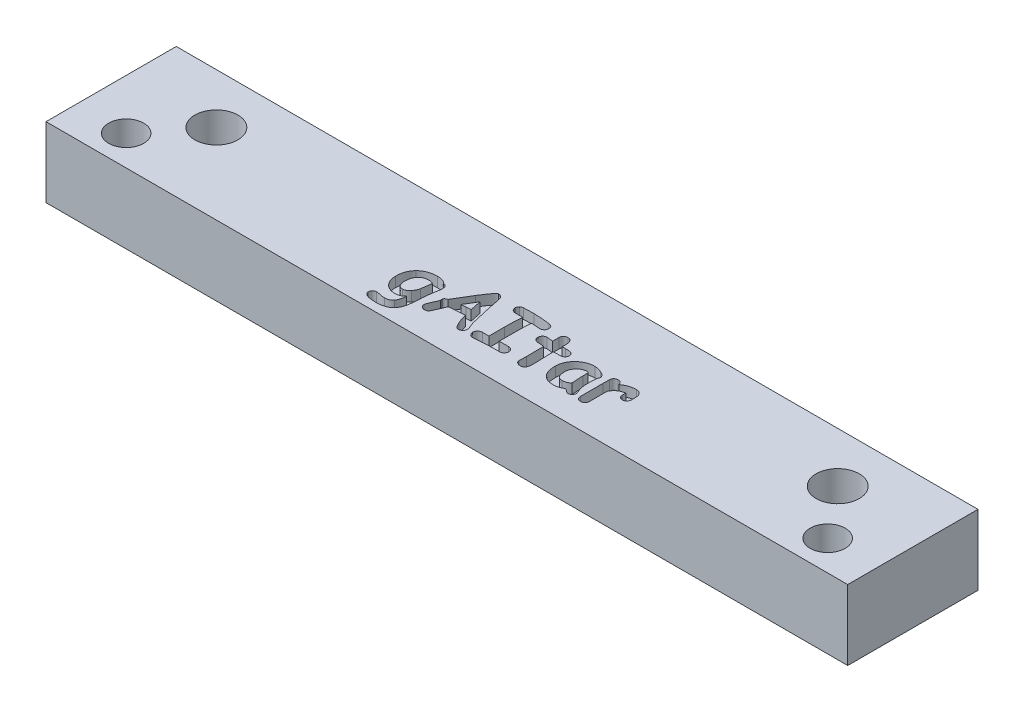
from build123d import *

# Parameters (mm, degrees)
SKETCH1_R           = 1.75
SKETCH1_R_2         = 2.15
BOSS_EXTRUDE1_DEPTH = 7
CUT_EXTRUDE1_DEPTH  = 1


with BuildPart() as part:
    # Sketch1 → Boss-Extrude1 (new body)
    with BuildSketch(Plane(origin=(0, 0, 0), x_dir=(1, 0, 0), z_dir=(0, 1, 0))):
        Polygon((-5.262861358, -24.280752379), (74.737138642, -24.280752379), (74.737138642, -37.280752379), (-5.262861358, -37.280752379), (-5.262861358, -36.780752379), align=None)
        with Locations((-0.262861358, -34.280752379)):
            Circle(SKETCH1_R, mode=Mode.SUBTRACT)
        with Locations((69.737138642, -34.280752379)):
            Circle(SKETCH1_R, mode=Mode.SUBTRACT)
        with Locations((3.737138642, -29.280752379)):
            Circle(SKETCH1_R_2, mode=Mode.SUBTRACT)
        with Locations((65.737138642, -29.280752379)):
            Circle(SKETCH1_R_2, mode=Mode.SUBTRACT)
    extrude(amount=-BOSS_EXTRUDE1_DEPTH)

    # Sketch2 → Cut-Extrude1 (cut)
    with BuildSketch(Plane(origin=(0, 0, 0), x_dir=(1, 0, 0), z_dir=(0, 1, 0))):
        with BuildLine():
            add(Edge.make_bspline(
                [(28.877942793, -32.540894307), (28.854196843, -32.673953942), (28.806150163, -32.943181901), (28.756806812, -33.35489831), (28.717322684, -33.776893115), (28.705414659, -34.062125424), (28.699392645, -34.20637041)],
                knots=[0, 0, 0, 0, 0.000405405, 0.000820281, 0.00124354, 0.001676578, 0.001676578, 0.001676578, 0.001676578], degree=3))
            add(Edge.make_bspline(
                [(28.699392645, -34.20637041), (28.695835472, -34.293705449), (28.688967863, -34.462317677), (28.66700685, -34.705919532), (28.636730362, -34.931090951), (28.597753156, -35.138010913), (28.548415725, -35.32603197), (28.489788382, -35.495464519), (28.423852115, -35.647606206), (28.368742547, -35.738131355), (28.342292349, -35.781579494)],
                knots=[0, 0, 0, 0, 0.000262191, 0.000506195, 0.000733457, 0.000943562, 0.001137489, 0.001315987, 0.001481163, 0.001633607, 0.001633607, 0.001633607, 0.001633607], degree=3))
            add(Edge.make_bspline(
                [(28.342292349, -35.781579494), (28.304156717, -35.834120572), (28.228319149, -35.93860521), (28.08648839, -36.07296206), (27.924012281, -36.185281957), (27.741415791, -36.278633239), (27.537219472, -36.349224454), (27.31309504, -36.400339071), (27.06817942, -36.431391059), (26.898115345, -36.434597207), (26.809736912, -36.43626337)],
                knots=[0, 0, 0, 0, 0.000194444, 0.000386677, 0.000582603, 0.000785341, 0.000999932, 0.001229002, 0.001473967, 0.001739002, 0.001739002, 0.001739002, 0.001739002], degree=3))
            add(Edge.make_bspline(
                [(26.809736912, -36.43626337), (26.757822527, -36.435865226), (26.65726388, -36.435094018), (26.511633725, -36.429685898), (26.376108667, -36.418024576), (26.250493435, -36.40523917), (26.135011767, -36.386120244), (26.029697641, -36.363469033), (25.93389223, -36.337336662), (25.848744625, -36.305110889), (25.7722405, -36.271205713), (25.706915296, -36.231051948), (25.650032596, -36.188884639), (25.604453101, -36.140433156), (25.569924709, -36.087279093), (25.543039988, -36.031277274), (25.527858641, -35.970176707), (25.526080351, -35.928137653), (25.525167791, -35.906564597)],
                knots=[0, 0, 0, 0, 0.000155748, 0.000301685, 0.000437031, 0.000563771, 0.00068037, 0.000787963, 0.000886884, 0.000977905, 0.001060903, 0.001137457, 0.001207493, 0.001272758, 0.00133576, 0.001397004, 0.001458353, 0.00152302, 0.00152302, 0.00152302, 0.00152302], degree=3))
            add(Edge.make_bspline(
                [(25.525167791, -35.906564597), (25.526215877, -35.87629543), (25.528227825, -35.818189517), (25.551639504, -35.736146405), (25.585673774, -35.661923106), (25.636625425, -35.599198201), (25.697788314, -35.547064507), (25.769772825, -35.510032387), (25.85046819, -35.487192991), (25.907236411, -35.485091336), (25.936825077, -35.483995914)],
                knots=[0, 0, 0, 0, 9.0534e-05, 0.000173792, 0.000254097, 0.000333879, 0.000414147, 0.000493565, 0.00057491, 0.000663466, 0.000663466, 0.000663466, 0.000663466], degree=3))
            add(Edge.make_bspline(
                [(25.936825077, -35.483995914), (25.963638071, -35.484919846), (26.023093997, -35.4869686), (26.119754504, -35.499958035), (26.232260846, -35.519849823), (26.355963241, -35.548043262), (26.484090778, -35.575933949), (26.609257658, -35.595667814), (26.726478353, -35.608437094), (26.802102599, -35.610143535), (26.838503324, -35.610964908)],
                knots=[0, 0, 0, 0, 8.0445e-05, 0.000178382, 0.000292214, 0.000423155, 0.000558946, 0.000685496, 0.000803149, 0.000912335, 0.000912335, 0.000912335, 0.000912335], degree=3))
            add(Edge.make_bspline(
                [(26.838503324, -35.610964908), (26.877567932, -35.610011313), (26.953309544, -35.608162407), (27.062525339, -35.594017403), (27.164376647, -35.571929801), (27.25734991, -35.537443735), (27.344008004, -35.49628974), (27.421574401, -35.443913826), (27.492510687, -35.383376968), (27.531879254, -35.335510928), (27.551711971, -35.311397437)],
                knots=[0, 0, 0, 0, 0.000117155, 0.000227149, 0.0003299, 0.000429055, 0.000523992, 0.000616981, 0.000709083, 0.000802584, 0.000802584, 0.000802584, 0.000802584], degree=3))
            add(Edge.make_bspline(
                [(27.551711971, -35.311397437), (27.569896668, -35.285681108), (27.60765942, -35.232277999), (27.653002314, -35.141279861), (27.694315296, -35.040298892), (27.727996695, -34.928090612), (27.758259393, -34.805399974), (27.781516807, -34.671465868), (27.799232941, -34.52642129), (27.806731843, -34.425959905), (27.810609686, -34.37400916)],
                knots=[0, 0, 0, 0, 9.4365e-05, 0.000195961, 0.000304088, 0.000421431, 0.000547017, 0.000683029, 0.00082895, 0.000985218, 0.000985218, 0.000985218, 0.000985218], degree=3))
            add(Edge.make_bspline(
                [(27.810609686, -34.37400916), (27.782698885, -34.401695192), (27.727347747, -34.456600581), (27.636014673, -34.528050168), (27.538772831, -34.587668052), (27.437572584, -34.637986756), (27.330231435, -34.675859988), (27.218052679, -34.701888829), (27.10129262, -34.720035356), (27.021753856, -34.72145877), (26.981343443, -34.722181949)],
                knots=[0, 0, 0, 0, 0.00011787, 0.000233754, 0.000346892, 0.000459573, 0.000572206, 0.000687451, 0.000804727, 0.000925846, 0.000925846, 0.000925846, 0.000925846], degree=3))
            add(Edge.make_bspline(
                [(26.981343443, -34.722181949), (26.928715985, -34.720777789), (26.825393462, -34.718021028), (26.67399483, -34.698437024), (26.530566129, -34.66336396), (26.394723539, -34.615394255), (26.265617077, -34.555215108), (26.145466336, -34.478931655), (26.032337381, -34.389967924), (25.927914025, -34.28800268), (25.833018923, -34.176043267), (25.751475247, -34.054333172), (25.680007527, -33.926616585), (25.624071676, -33.789363081), (25.578603755, -33.64556891), (25.549151631, -33.493399956), (25.527776408, -33.334724057), (25.526047619, -33.226074351), (25.525167791, -33.170779552)],
                knots=[0, 0, 0, 0, 0.000157872, 0.000309947, 0.000456946, 0.000600007, 0.000741553, 0.00088329, 0.001025971, 0.001172581, 0.001320418, 0.001465408, 0.00161147, 0.00175866, 0.001909259, 0.002063139, 0.002223085, 0.002388847, 0.002388847, 0.002388847, 0.002388847], degree=3))
            add(Edge.make_bspline(
                [(25.525167791, -33.170779552), (25.526887554, -33.096306694), (25.530261295, -32.950209702), (25.556533664, -32.736791613), (25.59873183, -32.534061071), (25.659225728, -32.342452474), (25.738560907, -32.162235251), (25.832463145, -31.991635336), (25.944982803, -31.832194811), (26.033254821, -31.736816392), (26.077681305, -31.688813323)],
                knots=[0, 0, 0, 0, 0.000223366, 0.000438188, 0.000644021, 0.000843855, 0.001039754, 0.001233795, 0.001427288, 0.001623345, 0.001623345, 0.001623345, 0.001623345], degree=3))
            add(Edge.make_bspline(
                [(26.077681305, -31.688813323), (26.126623805, -31.642038529), (26.223993806, -31.54898113), (26.387583037, -31.429806694), (26.562833435, -31.327778035), (26.751348872, -31.245446265), (26.952265678, -31.18185141), (27.165544243, -31.136712361), (27.391232899, -31.108125262), (27.546002792, -31.105107959), (27.625115921, -31.103565616)],
                knots=[0, 0, 0, 0, 0.000202913, 0.00040369, 0.000605473, 0.000810232, 0.001019476, 0.001236601, 0.001463479, 0.001700722, 0.001700722, 0.001700722, 0.001700722], degree=3))
            add(Edge.make_bspline(
                [(27.625115921, -31.103565616), (27.675732098, -31.104560502), (27.773198918, -31.106476261), (27.914326626, -31.119895566), (28.044017457, -31.144722103), (28.1634328, -31.178290006), (28.271952343, -31.221458981), (28.369629058, -31.275733024), (28.45670153, -31.339917156), (28.506269461, -31.390857667), (28.530761949, -31.416028375)],
                knots=[0, 0, 0, 0, 0.000151849, 0.000292401, 0.000424691, 0.000547456, 0.000664055, 0.000774178, 0.000881904, 0.000987125, 0.000987125, 0.000987125, 0.000987125], degree=3))
            add(Edge.make_bspline(
                [(28.530761949, -31.416028375), (28.56412149, -31.42109757), (28.627553929, -31.430736535), (28.714583395, -31.46367469), (28.78972595, -31.506896655), (28.850939812, -31.564983183), (28.897308072, -31.636572375), (28.929698255, -31.720321457), (28.949743161, -31.81617478), (28.952092305, -31.884119952), (28.953330633, -31.91993657)],
                knots=[0, 0, 0, 0, 0.000100969, 0.000191991, 0.00027739, 0.000359482, 0.000442569, 0.000531169, 0.00062747, 0.000734825, 0.000734825, 0.000734825, 0.000734825], degree=3))
            add(Edge.make_bspline(
                [(28.953330633, -31.91993657), (28.952146673, -31.960964891), (28.949572935, -32.050153848), (28.93454218, -32.194803585), (28.910557112, -32.360819589), (28.889249419, -32.478466591), (28.877942793, -32.540894307)],
                knots=[0, 0, 0, 0, 0.000123101, 0.000267602, 0.000435941, 0.000626255, 0.000626255, 0.000626255, 0.000626255], degree=3))
        make_face()
        with BuildLine():
            add(Edge.make_bspline(
                [(27.56659115, -31.865379581), (27.520897879, -31.866438657), (27.432118229, -31.868496386), (27.302839553, -31.886893976), (27.181391398, -31.916335625), (27.06739643, -31.957997772), (26.961687428, -32.012408784), (26.862456622, -32.076515818), (26.772331692, -32.154971826), (26.719478595, -32.214911306), (26.69268737, -32.245294618)],
                knots=[0, 0, 0, 0, 0.000137018, 0.000266218, 0.000390841, 0.000511353, 0.000629357, 0.000746834, 0.000864972, 0.000986415, 0.000986415, 0.000986415, 0.000986415], degree=3))
            add(Edge.make_bspline(
                [(26.69268737, -32.245294618), (26.670222313, -32.274607183), (26.625110774, -32.333469041), (26.568683583, -32.430563617), (26.521696421, -32.533923157), (26.480705607, -32.642858454), (26.452158703, -32.758926344), (26.430185117, -32.880815208), (26.41555868, -33.00907014), (26.414495131, -33.097003963), (26.41395075, -33.142013139)],
                knots=[0, 0, 0, 0, 0.000110707, 0.000222309, 0.000335929, 0.000451101, 0.000570914, 0.000693883, 0.000822595, 0.000957558, 0.000957558, 0.000957558, 0.000957558], degree=3))
            add(Edge.make_bspline(
                [(26.41395075, -33.142013139), (26.414223247, -33.175091726), (26.414749831, -33.23901425), (26.421850576, -33.331757851), (26.433363121, -33.417972092), (26.450416552, -33.497773343), (26.471296862, -33.571312332), (26.495229735, -33.639403995), (26.526734343, -33.699997687), (26.561304149, -33.755246201), (26.600972494, -33.804231754), (26.645911755, -33.845995073), (26.695443236, -33.881633978), (26.750140152, -33.909882252), (26.808830778, -33.933163075), (26.87257302, -33.948767141), (26.940667904, -33.959026479), (26.987916632, -33.959913895), (27.012093746, -33.960367984)],
                knots=[0, 0, 0, 0, 9.9214e-05, 0.000191726, 0.000278843, 0.00035997, 0.000436273, 0.000508139, 0.000576013, 0.00064068, 0.000703424, 0.000764483, 0.000824214, 0.00088589, 0.000948705, 0.001013181, 0.001082341, 0.001154814, 0.001154814, 0.001154814, 0.001154814], degree=3))
            add(Edge.make_bspline(
                [(27.012093746, -33.960367984), (27.035019407, -33.959534524), (27.081094772, -33.957859458), (27.149436886, -33.940123073), (27.218547523, -33.915948552), (27.286972543, -33.879200372), (27.356099105, -33.833464902), (27.42382951, -33.775837691), (27.494234949, -33.711012696), (27.537326333, -33.660944897), (27.559647533, -33.635009936)],
                knots=[0, 0, 0, 0, 6.8624e-05, 0.000137918, 0.000210716, 0.000287916, 0.000370176, 0.000458954, 0.000554387, 0.000656946, 0.000656946, 0.000656946, 0.000656946], degree=3))
            add(Edge.make_bspline(
                [(27.559647533, -33.635009936), (27.599829018, -33.58478111), (27.676709488, -33.488676753), (27.763963056, -33.333776212), (27.828525089, -33.181333794), (27.846515602, -33.076726335), (27.855247223, -33.025955543)],
                knots=[0, 0, 0, 0, 0.000192637, 0.000368578, 0.000531963, 0.000686044, 0.000686044, 0.000686044, 0.000686044], degree=3))
            add(Edge.make_bspline(
                [(27.855247223, -33.025955543), (27.860580778, -32.996535701), (27.871897159, -32.934114644), (27.888912402, -32.834990839), (27.905600452, -32.724135401), (27.923143748, -32.602081561), (27.942567757, -32.468289936), (27.960799418, -32.323005644), (27.980794396, -32.166298982), (27.994157711, -32.058152502), (28.001063177, -32.002268027)],
                knots=[0, 0, 0, 0, 8.9698e-05, 0.000190316, 0.000301706, 0.000425996, 0.000560246, 0.000707275, 0.000865253, 0.001034181, 0.001034181, 0.001034181, 0.001034181], degree=3))
            add(Edge.make_bspline(
                [(28.001063177, -32.002268027), (27.964183764, -31.981414951), (27.892722474, -31.941007915), (27.781348127, -31.899037579), (27.673103957, -31.871040303), (27.601466585, -31.867233068), (27.56659115, -31.865379581)],
                knots=[0, 0, 0, 0, 0.000126911, 0.000245915, 0.000356106, 0.000460642, 0.000460642, 0.000460642, 0.000460642], degree=3))
        make_face(mode=Mode.SUBTRACT)
        with BuildLine():
            add(Edge.make_bspline(
                [(33.235558349, -34.658697452), (33.213085251, -34.655922999), (33.16579916, -34.650085219), (33.097271021, -34.615554786), (33.030235064, -34.561916936), (32.963029355, -34.489879395), (32.897121064, -34.398047027), (32.829245877, -34.288319318), (32.762560867, -34.158249172), (32.720891322, -34.063762617), (32.69891596, -34.013933028)],
                knots=[0, 0, 0, 0, 6.7518e-05, 0.000142066, 0.000226194, 0.000324432, 0.000436526, 0.000564806, 0.000711214, 0.000874581, 0.000874581, 0.000874581, 0.000874581], degree=3))
            add(Edge.make_bspline(
                [(32.69891596, -34.013933028), (32.668678952, -33.943492327), (32.606585779, -33.798838907), (32.526783724, -33.570030748), (32.450362887, -33.326862355), (32.407460463, -33.158114419), (32.385461256, -33.071585025)],
                knots=[0, 0, 0, 0, 0.000229902, 0.000472116, 0.000726567, 0.000994359, 0.000994359, 0.000994359, 0.000994359], degree=3))
            add(Edge.make_bspline(
                [(32.385461256, -33.071585025), (32.36363523, -33.073866414), (32.317005321, -33.078740457), (32.242399118, -33.087273102), (32.15832511, -33.093696494), (32.064713346, -33.100408642), (31.961646204, -33.109065639), (31.848457362, -33.115080095), (31.725875988, -33.123821145), (31.640851197, -33.127965678), (31.596864769, -33.130109796)],
                knots=[0, 0, 0, 0, 6.5836e-05, 0.000140654, 0.000225254, 0.000318755, 0.000422222, 0.000535517, 0.000658774, 0.000790885, 0.000790885, 0.000790885, 0.000790885], degree=3))
            add(Edge.make_bspline(
                [(31.596864769, -33.130109796), (31.516163053, -33.134731794), (31.364592773, -33.143412621), (31.152339007, -33.160602013), (30.970009215, -33.177564735), (30.858825843, -33.191993113), (30.808268282, -33.198554019)],
                knots=[0, 0, 0, 0, 0.000242492, 0.000455437, 0.000638826, 0.000791759, 0.000791759, 0.000791759, 0.000791759], degree=3))
            add(Edge.make_bspline(
                [(30.808268282, -33.198554019), (30.794828271, -33.233978441), (30.766337857, -33.309071865), (30.718530049, -33.427528059), (30.662480037, -33.557981144), (30.601285389, -33.702087319), (30.53283589, -33.85848883), (30.457418118, -34.027594291), (30.373912335, -34.208408395), (30.316260097, -34.333338097), (30.286505071, -34.397815847)],
                knots=[0, 0, 0, 0, 0.000113663, 0.000240946, 0.000383178, 0.000539607, 0.000710628, 0.000895343, 0.001095079, 0.001308116, 0.001308116, 0.001308116, 0.001308116], degree=3))
            add(Edge.make_bspline(
                [(30.286505071, -34.397815847), (30.274140753, -34.418677312), (30.250255572, -34.458977139), (30.206859834, -34.511721017), (30.161143903, -34.556843152), (30.111883342, -34.594654701), (30.058051877, -34.623098439), (30.001157607, -34.644437967), (29.940493029, -34.656515609), (29.899037255, -34.657958897), (29.877823621, -34.658697452)],
                knots=[0, 0, 0, 0, 7.2656e-05, 0.000140356, 0.000204188, 0.000265094, 0.000325895, 0.000386151, 0.000446846, 0.000510455, 0.000510455, 0.000510455, 0.000510455], degree=3))
            add(Edge.make_bspline(
                [(29.877823621, -34.658697452), (29.847572379, -34.657222098), (29.787753699, -34.654304741), (29.700873959, -34.629343161), (29.619184688, -34.588638315), (29.544140857, -34.533985775), (29.478779045, -34.467283044), (29.431795607, -34.388769825), (29.401991228, -34.301362121), (29.399175264, -34.240012953), (29.397722112, -34.208354301)],
                knots=[0, 0, 0, 0, 9.0615e-05, 0.000179182, 0.000268793, 0.000363236, 0.000456547, 0.00054688, 0.000635652, 0.000730309, 0.000730309, 0.000730309, 0.000730309], degree=3))
            add(Edge.make_bspline(
                [(29.397722112, -34.208354301), (29.398197287, -34.200064303), (29.399289314, -34.181012577), (29.406068315, -34.149684959), (29.414659948, -34.111812385), (29.428081742, -34.067922709), (29.444924592, -34.017313403), (29.46592299, -33.960277163), (29.489485224, -33.89656729), (29.517656287, -33.826942963), (29.549317512, -33.750524182), (29.585177114, -33.667735674), (29.62336015, -33.577940046), (29.667763538, -33.483015774), (29.714304145, -33.380811795), (29.763302797, -33.271443227), (29.818377864, -33.156924541), (29.855707718, -33.07821532), (29.874847786, -33.037858886)],
                knots=[0, 0, 0, 0, 2.4878e-05, 5.7173e-05, 9.591e-05, 0.000141421, 0.000194746, 0.000255934, 0.000323736, 0.000398521, 0.000481234, 0.000571887, 0.000669184, 0.000773936, 0.000886241, 0.001006098, 0.001133442, 0.001267439, 0.001267439, 0.001267439, 0.001267439], degree=3))
            add(Edge.make_bspline(
                [(29.874847786, -33.037858886), (29.861734206, -33.004229741), (29.837071083, -32.940982345), (29.835776308, -32.87319704), (29.835169975, -32.841453723)],
                knots=[0, 0, 0, 0, 0.000107286, 0.000201776, 0.000201776, 0.000201776, 0.000201776], degree=3))
            add(Edge.make_bspline(
                [(29.835169975, -32.841453723), (29.83715775, -32.828046189), (29.841129712, -32.801255315), (29.859313247, -32.763472656), (29.88607645, -32.728030181), (29.921555436, -32.694707703), (29.96695822, -32.664724608), (30.020447717, -32.636274244), (30.083036467, -32.609314591), (30.128633408, -32.595024504), (30.15259246, -32.587515735)],
                knots=[0, 0, 0, 0, 4.0464e-05, 8.0854e-05, 0.000124103, 0.000173222, 0.000226047, 0.000286848, 0.000354838, 0.000430121, 0.000430121, 0.000430121, 0.000430121], degree=3))
            add(Edge.make_bspline(
                [(30.15259246, -32.587515735), (30.231423481, -32.447348907), (30.391344152, -32.162999259), (30.64431192, -31.736392074), (30.907176387, -31.300193503), (31.091084651, -31.009652482), (31.184215538, -30.862522916)],
                knots=[0, 0, 0, 0, 0.000482425, 0.000978672, 0.001487838, 0.002010204, 0.002010204, 0.002010204, 0.002010204], degree=3))
            add(Edge.make_bspline(
                [(31.184215538, -30.862522916), (31.217099316, -30.810494261), (31.280851486, -30.709625693), (31.376479011, -30.564934089), (31.466866571, -30.429774946), (31.551859782, -30.304473204), (31.630997039, -30.188204561), (31.707715618, -30.08399507), (31.777822594, -29.988270602), (31.843469979, -29.903090817), (31.903297517, -29.827123076), (31.960625012, -29.762915863), (32.01111064, -29.70684619), (32.058565988, -29.66274709), (32.098467449, -29.625147234), (32.136209533, -29.60111765), (32.168177992, -29.583842409), (32.188916016, -29.581125597), (32.1979836, -29.579937686)],
                knots=[0, 0, 0, 0, 0.000184643, 0.00035797, 0.000520288, 0.000672432, 0.000812208, 0.000942168, 0.001060609, 0.001168142, 0.00126481, 0.001350566, 0.00142637, 0.001490915, 0.001545038, 0.001590158, 0.001625214, 0.001652452, 0.001652452, 0.001652452, 0.001652452], degree=3))
            add(Edge.make_bspline(
                [(32.1979836, -29.579937686), (32.228198034, -29.581159141), (32.286434526, -29.583513421), (32.370152837, -29.604924833), (32.445134893, -29.641325836), (32.513508541, -29.690659032), (32.571711746, -29.755875543), (32.624379663, -29.832991266), (32.666444462, -29.92567341), (32.687746456, -29.992996635), (32.69891596, -30.028296947)],
                knots=[0, 0, 0, 0, 9.0534e-05, 0.000174498, 0.000257021, 0.000339358, 0.000425703, 0.000517868, 0.000618603, 0.000729648, 0.000729648, 0.000729648, 0.000729648], degree=3))
            add(Edge.make_bspline(
                [(32.69891596, -30.028296947), (32.704808779, -30.060050457), (32.717339507, -30.127572402), (32.738446869, -30.234255361), (32.760968037, -30.352749286), (32.787095376, -30.482232375), (32.814440867, -30.62323987), (32.845636158, -30.774852192), (32.878094052, -30.937984513), (32.901207691, -31.050344397), (32.913176138, -31.108525342)],
                knots=[0, 0, 0, 0, 9.6886e-05, 0.000206023, 0.000326249, 0.000458728, 0.000602297, 0.000757148, 0.000923088, 0.001101285, 0.001101285, 0.001101285, 0.001101285], degree=3))
            add(Edge.make_bspline(
                [(32.913176138, -31.108525342), (32.931074412, -31.190847205), (32.967518604, -31.358469722), (33.02229726, -31.614377957), (33.082692092, -31.87822508), (33.143880396, -32.151485062), (33.208234647, -32.433558163), (33.275678925, -32.724202097), (33.346362889, -33.023379985), (33.394566849, -33.225675147), (33.419068224, -33.328498849)],
                knots=[0, 0, 0, 0, 0.000252736, 0.000514617, 0.000785104, 0.001064735, 0.001354699, 0.001653064, 0.001959833, 0.002276941, 0.002276941, 0.002276941, 0.002276941], degree=3))
            add(Edge.make_bspline(
                [(33.419068224, -33.328498849), (33.421631011, -33.337782168), (33.427533411, -33.359162734), (33.439782742, -33.394788748), (33.455437577, -33.438193712), (33.476001602, -33.489502246), (33.499345643, -33.549067428), (33.526005027, -33.617173934), (33.558091525, -33.692290248), (33.580748465, -33.745119387), (33.592658645, -33.772890329)],
                knots=[0, 0, 0, 0, 2.8886e-05, 6.6528e-05, 0.000112969, 0.000167309, 0.000232333, 0.000304908, 0.000386706, 0.000477359, 0.000477359, 0.000477359, 0.000477359], degree=3))
            add(Edge.make_bspline(
                [(33.592658645, -33.772890329), (33.611160977, -33.81795666), (33.645239289, -33.90096158), (33.683228868, -34.018937349), (33.708323585, -34.118714237), (33.71272017, -34.180146899), (33.714667913, -34.207362355)],
                knots=[0, 0, 0, 0, 0.000146072, 0.000269041, 0.000371793, 0.000453518, 0.000453518, 0.000453518, 0.000453518], degree=3))
            add(Edge.make_bspline(
                [(33.714667913, -34.207362355), (33.713107891, -34.238663553), (33.710037989, -34.300259879), (33.681008737, -34.38806705), (33.633882952, -34.467791259), (33.570011706, -34.536479059), (33.495104561, -34.593193592), (33.412833497, -34.63309552), (33.325609111, -34.657783385), (33.265809255, -34.658390388), (33.235558349, -34.658697452)],
                knots=[0, 0, 0, 0, 9.3669e-05, 0.000184328, 0.000274152, 0.000369637, 0.000463872, 0.000554373, 0.000642678, 0.000733081, 0.000733081, 0.000733081, 0.000733081], degree=3))
        make_face()
        with BuildLine():
            add(Edge.make_bspline(
                [(31.962892572, -31.184905128), (31.940083643, -31.222933217), (31.8924824, -31.302296188), (31.817986798, -31.426228938), (31.738121758, -31.560303444), (31.650024121, -31.703115187), (31.557210217, -31.856796891), (31.458200348, -32.020249344), (31.352615291, -32.1934437), (31.280114464, -32.31209226), (31.242740309, -32.373255557)],
                knots=[0, 0, 0, 0, 0.000133032, 0.000277631, 0.000433799, 0.0006012, 0.000781016, 0.000972399, 0.001174503, 0.001389538, 0.001389538, 0.001389538, 0.001389538], degree=3))
            add(Edge.make_bspline(
                [(31.242740309, -32.373255557), (31.271493621, -32.369521639), (31.335515792, -32.36120769), (31.442240508, -32.349782814), (31.570071468, -32.343179353), (31.662336832, -32.338224774), (31.71193042, -32.335561637)],
                knots=[0, 0, 0, 0, 8.6986e-05, 0.000193684, 0.000321891, 0.000470894, 0.000470894, 0.000470894, 0.000470894], degree=3))
            add(Edge.make_bspline(
                [(31.71193042, -32.335561637), (31.742020216, -32.334258402), (31.799229947, -32.331780562), (31.880578357, -32.327958139), (31.953282168, -32.323562699), (32.0174642, -32.320972205), (32.073009618, -32.317910808), (32.1196502, -32.315151149), (32.157624746, -32.31181437), (32.180125964, -32.310396347), (32.190048038, -32.30977106)],
                knots=[0, 0, 0, 0, 9.0354e-05, 0.00017179, 0.000244311, 0.000308856, 0.000364485, 0.000411201, 0.000449012, 0.000478837, 0.000478837, 0.000478837, 0.000478837], degree=3))
            add(Edge.make_bspline(
                [(32.190048038, -32.30977106), (32.182709621, -32.272420168), (32.167519966, -32.195108246), (32.145162681, -32.074535266), (32.119121851, -31.94602406), (32.091177844, -31.809568376), (32.062888541, -31.664843101), (32.030304669, -31.512391009), (31.998591149, -31.35101844), (31.974964924, -31.241080431), (31.962892572, -31.184905128)],
                knots=[0, 0, 0, 0, 0.000114194, 0.000236369, 0.000367876, 0.000507553, 0.000654234, 0.000810256, 0.000975224, 0.001147594, 0.001147594, 0.001147594, 0.001147594], degree=3))
        make_face(mode=Mode.SUBTRACT)
        with BuildLine():
            add(Edge.make_bspline(
                [(37.268807804, -30.532205142), (37.252272893, -30.531957349), (37.213563435, -30.531377247), (37.146772385, -30.528022193), (37.062456369, -30.523051082), (36.960287926, -30.516013995), (36.840264568, -30.507044342), (36.702712621, -30.496141421), (36.54764323, -30.483177666), (36.438546891, -30.473712133), (36.38101679, -30.468720645)],
                knots=[0, 0, 0, 0, 4.9607e-05, 0.000116134, 0.000200595, 0.000303001, 0.000423358, 0.00056167, 0.000716949, 0.000890188, 0.000890188, 0.000890188, 0.000890188], degree=3))
            add(Edge.make_bspline(
                [(36.38101679, -30.468720645), (36.376156077, -30.522598524), (36.366024455, -30.634901029), (36.354963277, -30.809912687), (36.343193677, -30.99765482), (36.336312134, -31.198118174), (36.32846523, -31.41134925), (36.325478824, -31.637229366), (36.321910669, -31.87594946), (36.321639498, -32.039298856), (36.321500074, -32.12328535)],
                knots=[0, 0, 0, 0, 0.000162282, 0.00033826, 0.000526055, 0.000726585, 0.000939966, 0.001166164, 0.00140425, 0.001656206, 0.001656206, 0.001656206, 0.001656206], degree=3))
            Line((36.321500074, -32.12328535), (36.317532293, -33.642945499))
            add(Edge.make_bspline(
                [(36.317532293, -33.642945499), (36.469955875, -33.639805985), (36.777756784, -33.63346612), (37.085623028, -33.633173673), (37.241033336, -33.633026046)],
                knots=[0, 0, 0, 0, 0.000457356, 0.000923574, 0.000923574, 0.000923574, 0.000923574], degree=3))
            add(Edge.make_bspline(
                [(37.241033336, -33.633026046), (37.273952602, -33.634313678), (37.337511462, -33.636799774), (37.428256671, -33.662874302), (37.510319106, -33.704882895), (37.580640492, -33.764113391), (37.640839134, -33.832175579), (37.682604017, -33.910514288), (37.710622821, -33.99484723), (37.712982467, -34.054039225), (37.714191229, -34.084361142)],
                knots=[0, 0, 0, 0, 9.8523e-05, 0.000190223, 0.000280729, 0.000373065, 0.000464518, 0.000551521, 0.000637798, 0.000728413, 0.000728413, 0.000728413, 0.000728413], degree=3))
            add(Edge.make_bspline(
                [(37.714191229, -34.084361142), (37.712384579, -34.114283345), (37.708846495, -34.172882036), (37.683349659, -34.257990383), (37.63860033, -34.334810698), (37.578711728, -34.403060375), (37.507162885, -34.460949206), (37.42375185, -34.501921139), (37.33185584, -34.527882927), (37.267335467, -34.53042077), (37.23408972, -34.531728458)],
                knots=[0, 0, 0, 0, 8.972e-05, 0.000175705, 0.000263676, 0.000354378, 0.000446863, 0.000537804, 0.000631415, 0.000730926, 0.000730926, 0.000730926, 0.000730926], degree=3))
            add(Edge.make_bspline(
                [(37.23408972, -34.531728458), (37.197717239, -34.531586157), (37.11703153, -34.53127049), (36.983795027, -34.534218824), (36.826380739, -34.535187935), (36.652825741, -34.540214935), (36.479540889, -34.542076832), (36.322506729, -34.54605818), (36.189569162, -34.546400648), (36.108892643, -34.54722703), (36.072521812, -34.547599582)],
                knots=[0, 0, 0, 0, 0.000109114, 0.000242049, 0.000399781, 0.000581351, 0.000762901, 0.000919657, 0.001052581, 0.001161699, 0.001161699, 0.001161699, 0.001161699], degree=3))
            add(Edge.make_bspline(
                [(36.072521812, -34.547599582), (36.052352937, -34.547909932), (36.009694024, -34.548566349), (35.941841258, -34.550043431), (35.86685545, -34.555864593), (35.784454403, -34.561235381), (35.69525761, -34.569813705), (35.598888357, -34.577943188), (35.495560077, -34.590778028), (35.387392638, -34.60291631), (35.279059053, -34.616227316), (35.175464927, -34.62655225), (35.079319224, -34.636881273), (34.990368407, -34.644856638), (34.908361434, -34.650975539), (34.833260272, -34.65453743), (34.765500093, -34.658090119), (34.722819012, -34.658502524), (34.702645399, -34.658697452)],
                knots=[0, 0, 0, 0, 6.0517e-05, 0.000127998, 0.000203549, 0.000286095, 0.000375722, 0.000472354, 0.000576201, 0.000688045, 0.000798903, 0.000903628, 0.001000356, 0.001088995, 0.001171542, 0.001247034, 0.001314552, 0.001375069, 0.001375069, 0.001375069, 0.001375069], degree=3))
            add(Edge.make_bspline(
                [(34.702645399, -34.658697452), (34.669399608, -34.657031214), (34.604816187, -34.653794375), (34.512162107, -34.627031563), (34.428642369, -34.582912294), (34.356267373, -34.521860117), (34.297152185, -34.449035927), (34.25324556, -34.367429026), (34.227883251, -34.277948244), (34.224348534, -34.216115975), (34.22254389, -34.184547614)],
                knots=[0, 0, 0, 0, 9.9595e-05, 0.000193475, 0.000286659, 0.000381025, 0.000475525, 0.000566493, 0.000657238, 0.000751895, 0.000751895, 0.000751895, 0.000751895], degree=3))
            add(Edge.make_bspline(
                [(34.22254389, -34.184547614), (34.224157438, -34.152595628), (34.227327377, -34.089823509), (34.255489115, -34.00011529), (34.299941485, -33.917330953), (34.362784832, -33.845175494), (34.437593343, -33.783191236), (34.524206432, -33.737670911), (34.620793103, -33.711439956), (34.687936917, -33.708132021), (34.722484304, -33.706429996)],
                knots=[0, 0, 0, 0, 9.5644e-05, 0.000187901, 0.000279337, 0.00037574, 0.000473031, 0.000569311, 0.000667012, 0.00077056, 0.00077056, 0.00077056, 0.00077056], degree=3))
            add(Edge.make_bspline(
                [(34.722484304, -33.706429996), (34.766460544, -33.706429996), (34.860695345, -33.706429996), (35.011801674, -33.706429996), (35.182085611, -33.706429996), (35.302110988, -33.706429996), (35.365264837, -33.706429996)],
                knots=[0, 0, 0, 0, 0.000131929, 0.000282704, 0.000453319, 0.000642781, 0.000642781, 0.000642781, 0.000642781], degree=3))
            add(Edge.make_bspline(
                [(35.365264837, -33.706429996), (35.364511819, -33.669067888), (35.362859295, -33.587075398), (35.362322094, -33.452491049), (35.361196517, -33.295104233), (35.360245326, -33.114569489), (35.359314094, -32.910890075), (35.358015335, -32.684397081), (35.358409471, -32.43475598), (35.358351518, -32.260835031), (35.35832122, -32.169906778)],
                knots=[0, 0, 0, 0, 0.000112107, 0.000246024, 0.000403746, 0.000584283, 0.000787634, 0.001014792, 0.00126377, 0.001536555, 0.001536555, 0.001536555, 0.001536555], degree=3))
            add(Edge.make_bspline(
                [(35.35832122, -32.169906778), (35.358866836, -32.017464216), (35.359945285, -31.716150158), (35.375043284, -31.269728718), (35.395669319, -30.833757721), (35.417802681, -30.547040105), (35.428749334, -30.405236148)],
                knots=[0, 0, 0, 0, 0.000457304, 0.000903895, 0.001339906, 0.00176656, 0.00176656, 0.00176656, 0.00176656], degree=3))
            Line((35.428749334, -30.405236148), (34.697685672, -30.405236148))
            add(Edge.make_bspline(
                [(34.697685672, -30.405236148), (34.665131956, -30.40376645), (34.602144129, -30.400922748), (34.51158525, -30.377218236), (34.428996951, -30.338461694), (34.357277453, -30.283619854), (34.296783195, -30.218506073), (34.253671242, -30.143151387), (34.227600026, -30.059725332), (34.224265293, -30.00170593), (34.22254389, -29.971756066)],
                knots=[0, 0, 0, 0, 9.7534e-05, 0.000188717, 0.000278788, 0.000369452, 0.00045793, 0.000543686, 0.000627773, 0.000717494, 0.000717494, 0.000717494, 0.000717494], degree=3))
            add(Edge.make_bspline(
                [(34.22254389, -29.971756066), (34.223877722, -29.941798043), (34.226477059, -29.883416636), (34.25227026, -29.800908996), (34.29358521, -29.726380659), (34.333240873, -29.686560614), (34.353480665, -29.666236924)],
                knots=[0, 0, 0, 0, 8.9627e-05, 0.000174663, 0.000256851, 0.000342526, 0.000342526, 0.000342526, 0.000342526], degree=3))
            add(Edge.make_bspline(
                [(34.353480665, -29.666236924), (34.374443248, -29.649260209), (34.416023906, -29.615585781), (34.488402012, -29.578471252), (34.567641076, -29.553408521), (34.623450452, -29.546027165), (34.65205619, -29.542243766)],
                knots=[0, 0, 0, 0, 8.0745e-05, 0.000160162, 0.000242356, 0.000328786, 0.000328786, 0.000328786, 0.000328786], degree=3))
            add(Edge.make_bspline(
                [(34.65205619, -29.542243766), (34.678168585, -29.540125364), (34.734976877, -29.535516719), (34.827292817, -29.531140789), (34.932743109, -29.525939444), (35.051450359, -29.521777526), (35.183409994, -29.520458291), (35.328892096, -29.518421514), (35.487597405, -29.515895522), (35.597709578, -29.516262529), (35.654912855, -29.516453189)],
                knots=[0, 0, 0, 0, 7.8589e-05, 0.000170974, 0.000277227, 0.000395336, 0.000527279, 0.000673109, 0.000831832, 0.001003439, 0.001003439, 0.001003439, 0.001003439], degree=3))
            add(Edge.make_bspline(
                [(35.654912855, -29.516453189), (35.710466599, -29.516860403), (35.825240583, -29.517701705), (36.003160384, -29.524052855), (36.192646053, -29.533998497), (36.394027651, -29.548014984), (36.606985662, -29.565877929), (36.831495405, -29.587883591), (37.067280086, -29.613537274), (37.228160937, -29.633307499), (37.310469505, -29.643422183)],
                knots=[0, 0, 0, 0, 0.000166659, 0.000344317, 0.000534038, 0.000735881, 0.000949895, 0.001175134, 0.001412622, 0.001661403, 0.001661403, 0.001661403, 0.001661403], degree=3))
            add(Edge.make_bspline(
                [(37.310469505, -29.643422183), (37.342146666, -29.648626944), (37.402793314, -29.658591576), (37.485767414, -29.68994583), (37.556758363, -29.730582156), (37.615386226, -29.782553274), (37.660684891, -29.846334591), (37.69228992, -29.921151494), (37.711509863, -30.006173961), (37.71326813, -30.066212565), (37.714191229, -30.097733115)],
                knots=[0, 0, 0, 0, 9.6101e-05, 0.000183988, 0.000264458, 0.000340327, 0.000417124, 0.000497097, 0.000582526, 0.000676948, 0.000676948, 0.000676948, 0.000676948], degree=3))
            add(Edge.make_bspline(
                [(37.714191229, -30.097733115), (37.712338292, -30.131025261), (37.708741971, -30.195641185), (37.679263419, -30.286989826), (37.6295168, -30.367726797), (37.58248112, -30.408968818), (37.558455822, -30.43003478)],
                knots=[0, 0, 0, 0, 9.9689e-05, 0.000193484, 0.000284857, 0.000380259, 0.000380259, 0.000380259, 0.000380259], degree=3))
            add(Edge.make_bspline(
                [(37.558455822, -30.43003478), (37.53678496, -30.445724093), (37.494447936, -30.476375334), (37.422730132, -30.508404001), (37.347377422, -30.52932078), (37.295068386, -30.531241092), (37.268807804, -30.532205142)],
                knots=[0, 0, 0, 0, 8.0059e-05, 0.000156407, 0.000234361, 0.000312951, 0.000312951, 0.000312951, 0.000312951], degree=3))
        make_face()
        with BuildLine():
            add(Edge.make_bspline(
                [(40.603727791, -31.849508456), (40.577601549, -31.849358625), (40.520693131, -31.849032261), (40.433442511, -31.844580349), (40.346195595, -31.84004498), (40.289617041, -31.839733046), (40.263490564, -31.839589004)],
                knots=[0, 0, 0, 0, 7.837e-05, 0.000170706, 0.000262051, 0.000340421, 0.000340421, 0.000340421, 0.000340421], degree=3))
            add(Edge.make_bspline(
                [(40.263490564, -31.839589004), (40.212503888, -31.840695924), (40.102916162, -31.843075072), (39.994254481, -31.857608149), (39.936148626, -31.865379581)],
                knots=[0, 0, 0, 0, 0.000152875, 0.000328581, 0.000328581, 0.000328581, 0.000328581], degree=3))
            add(Edge.make_bspline(
                [(39.936148626, -31.865379581), (39.940951192, -31.971841327), (39.950122744, -32.175153398), (39.960518047, -32.465841199), (39.970314926, -32.727388083), (39.979940407, -32.960116859), (39.985739313, -33.163820366), (39.9894038, -33.338747292), (39.992959223, -33.48455153), (39.993458952, -33.572185196), (39.993681452, -33.61120325)],
                knots=[0, 0, 0, 0, 0.000319708, 0.000610553, 0.000872614, 0.001104901, 0.001309328, 0.001483956, 0.001629802, 0.001746856, 0.001746856, 0.001746856, 0.001746856], degree=3))
            add(Edge.make_bspline(
                [(39.993681452, -33.61120325), (39.993625631, -33.61980091), (39.993492492, -33.640307613), (39.994906863, -33.675674972), (39.995731003, -33.720646461), (39.99693329, -33.789093087), (39.998704809, -33.870425553), (39.999349577, -33.933584732), (39.999633123, -33.961359929)],
                knots=[0, 0, 0, 0, 2.5791e-05, 6.1514e-05, 0.000106163, 0.000160729, 0.000266886, 0.000350215, 0.000350215, 0.000350215, 0.000350215], degree=3))
            add(Edge.make_bspline(
                [(39.999633123, -33.961359929), (39.998414463, -34.020975704), (39.99612721, -34.132866133), (39.971717058, -34.288702353), (39.931753847, -34.421352414), (39.875471858, -34.531157396), (39.801480848, -34.618242581), (39.708973762, -34.679324545), (39.599923513, -34.716425546), (39.521824626, -34.720200967), (39.480845749, -34.722181949)],
                knots=[0, 0, 0, 0, 0.000178726, 0.000335444, 0.000471605, 0.00059274, 0.000703132, 0.000810427, 0.000921472, 0.00104406, 0.00104406, 0.00104406, 0.00104406], degree=3))
            add(Edge.make_bspline(
                [(39.480845749, -34.722181949), (39.448926941, -34.721110253), (39.386928599, -34.719028617), (39.298021024, -34.69509952), (39.214107132, -34.661998537), (39.165774812, -34.626736952), (39.141600467, -34.609100188)],
                knots=[0, 0, 0, 0, 9.548e-05, 0.000185457, 0.000274809, 0.000364222, 0.000364222, 0.000364222, 0.000364222], degree=3))
            add(Edge.make_bspline(
                [(39.141600467, -34.609100188), (39.117272631, -34.589045268), (39.070606164, -34.550575249), (39.0213802, -34.476348269), (38.989075706, -34.395752823), (38.985633144, -34.338612386), (38.98388117, -34.309532718)],
                knots=[0, 0, 0, 0, 9.4083e-05, 0.000180474, 0.000264297, 0.000351165, 0.000351165, 0.000351165, 0.000351165], degree=3))
            add(Edge.make_bspline(
                [(38.98388117, -34.309532718), (38.984169079, -34.287047866), (38.984808471, -34.237113269), (38.986905826, -34.15478089), (38.989982774, -34.057573221), (38.993426, -33.950420479), (38.999037715, -33.843023142), (39.001585402, -33.745450988), (39.003801837, -33.662792514), (39.004429426, -33.612857458), (39.004712021, -33.590372399)],
                knots=[0, 0, 0, 0, 6.746e-05, 0.000149815, 0.000247071, 0.000359231, 0.000471431, 0.000569678, 0.000652034, 0.000719493, 0.000719493, 0.000719493, 0.000719493], degree=3))
            add(Edge.make_bspline(
                [(39.004712021, -33.590372399), (39.0047636, -33.552017072), (39.004879654, -33.465716446), (39.003767426, -33.321881818), (39.001470274, -33.149290357), (38.999839012, -32.947917877), (38.996771058, -32.718117018), (38.992473782, -32.459559742), (38.988900792, -32.172215553), (38.98560668, -31.970855359), (38.98388117, -31.865379581)],
                knots=[0, 0, 0, 0, 0.000115066, 0.000258901, 0.000431511, 0.000632886, 0.000863036, 0.001120973, 0.001408664, 0.001725133, 0.001725133, 0.001725133, 0.001725133], degree=3))
            add(Edge.make_bspline(
                [(38.98388117, -31.865379581), (38.943528545, -31.863266021), (38.85381441, -31.858567042), (38.705745274, -31.845864456), (38.530482911, -31.829805826), (38.370387325, -31.815316083), (38.238747402, -31.796105773), (38.149135286, -31.768877817), (38.073524549, -31.728837699), (38.011025542, -31.678265384), (37.962185442, -31.616434072), (37.928169852, -31.543089835), (37.908359171, -31.459053128), (37.905923033, -31.39960775), (37.90464472, -31.368415002)],
                knots=[0, 0, 0, 0, 0.000121216, 0.000269495, 0.000445785, 0.000649211, 0.000751785, 0.000844334, 0.00092865, 0.001006888, 0.001083883, 0.001162866, 0.001247554, 0.001341055, 0.001341055, 0.001341055, 0.001341055], degree=3))
            add(Edge.make_bspline(
                [(37.90464472, -31.368415002), (37.905896631, -31.337777893), (37.908353553, -31.277651434), (37.935979494, -31.19187548), (37.977789769, -31.112760057), (38.037201712, -31.043941382), (38.107915409, -30.984429047), (38.191959092, -30.942800228), (38.285344752, -30.916913794), (38.350841725, -30.914408823), (38.384746229, -30.913112125)],
                knots=[0, 0, 0, 0, 9.1603e-05, 0.000179775, 0.00026765, 0.000358461, 0.000450797, 0.000543069, 0.000637638, 0.000739127, 0.000739127, 0.000739127, 0.000739127], degree=3))
            add(Edge.make_bspline(
                [(38.384746229, -30.913112125), (38.397314297, -30.913355151), (38.426113284, -30.913912032), (38.474398319, -30.917165938), (38.53357541, -30.922283416), (38.603032833, -30.929096072), (38.683351073, -30.938322053), (38.773968633, -30.949083869), (38.875464886, -30.962101705), (38.946522575, -30.971601895), (38.98388117, -30.976596622)],
                knots=[0, 0, 0, 0, 3.7707e-05, 8.6403e-05, 0.000145138, 0.000215907, 0.000295764, 0.000387673, 0.000489669, 0.000602743, 0.000602743, 0.000602743, 0.000602743], degree=3))
            add(Edge.make_bspline(
                [(38.98388117, -30.976596622), (38.98388117, -30.956427068), (38.98388117, -30.910797586), (38.98388117, -30.833756503), (38.98388117, -30.740183), (38.98388117, -30.672069425), (38.98388117, -30.63536745)],
                knots=[0, 0, 0, 0, 6.0509e-05, 0.000136888, 0.000231123, 0.000341229, 0.000341229, 0.000341229, 0.000341229], degree=3))
            add(Edge.make_bspline(
                [(38.98388117, -30.63536745), (38.98388117, -30.602963905), (38.98388117, -30.541793946), (38.98388117, -30.456156005), (38.98388117, -30.382090758), (38.98388117, -30.336791925), (38.98388117, -30.315961074)],
                knots=[0, 0, 0, 0, 9.7211e-05, 0.00018351, 0.000256914, 0.000319406, 0.000319406, 0.000319406, 0.000319406], degree=3))
            add(Edge.make_bspline(
                [(38.98388117, -30.315961074), (38.985702663, -30.287033236), (38.989269658, -30.230384429), (39.01428143, -30.149039435), (39.058941835, -30.07683258), (39.118609647, -30.013845186), (39.18988812, -29.961785146), (39.270531698, -29.924556361), (39.357782924, -29.90053949), (39.418852685, -29.898436197), (39.450095445, -29.897360171)],
                knots=[0, 0, 0, 0, 8.676e-05, 0.0001699, 0.000252237, 0.000339258, 0.000428742, 0.000515275, 0.000604539, 0.00069804, 0.00069804, 0.00069804, 0.00069804], degree=3))
            add(Edge.make_bspline(
                [(39.450095445, -29.897360171), (39.469986253, -29.897791935), (39.508711956, -29.898632542), (39.56489859, -29.909256329), (39.617372828, -29.924614175), (39.666197747, -29.946930795), (39.710740833, -29.975890744), (39.752169781, -30.010890514), (39.788315309, -30.052960657), (39.82215387, -30.100292867), (39.850188749, -30.155046837), (39.875127966, -30.215762347), (39.895530726, -30.282669384), (39.913642147, -30.35540656), (39.927553878, -30.434595535), (39.935707324, -30.520505439), (39.942137084, -30.61245697), (39.942767486, -30.676024254), (39.943092243, -30.7087714)],
                knots=[0, 0, 0, 0, 5.9591e-05, 0.000116019, 0.000170935, 0.000223311, 0.000276415, 0.000329888, 0.000385411, 0.000442376, 0.000504053, 0.000569446, 0.000639094, 0.000713675, 0.000794237, 0.00088001, 0.000972453, 0.001070675, 0.001070675, 0.001070675, 0.001070675], degree=3))
            Line((39.943092243, -30.7087714), (39.936148626, -30.976596622))
            add(Edge.make_bspline(
                [(39.936148626, -30.976596622), (39.969544117, -30.976596622), (40.033028614, -30.976596622), (40.123295633, -30.976596622), (40.2036432, -30.976596622), (40.25390176, -30.976596622), (40.277377798, -30.976596622)],
                knots=[0, 0, 0, 0, 0.000100186, 0.000190453, 0.000270801, 0.000341229, 0.000341229, 0.000341229, 0.000341229], degree=3))
            add(Edge.make_bspline(
                [(40.277377798, -30.976596622), (40.308458573, -30.976875952), (40.36798103, -30.977410895), (40.45365934, -30.978993608), (40.5316834, -30.983266133), (40.602189, -30.987800651), (40.664784796, -30.994538528), (40.719323518, -31.003599605), (40.766427199, -31.013197832), (40.794883796, -31.021401128), (40.808068516, -31.02520194)],
                knots=[0, 0, 0, 0, 9.3248e-05, 0.000178578, 0.000257043, 0.000327645, 0.000390522, 0.000445805, 0.00049347, 0.000534621, 0.000534621, 0.000534621, 0.000534621], degree=3))
            add(Edge.make_bspline(
                [(40.808068516, -31.02520194), (40.829561551, -31.033088184), (40.87101087, -31.048296807), (40.926067439, -31.082041058), (40.974169496, -31.120932417), (41.012814933, -31.168020196), (41.043131564, -31.221359918), (41.063942782, -31.28153411), (41.07705278, -31.348005024), (41.078250253, -31.394801523), (41.078869573, -31.419004211)],
                knots=[0, 0, 0, 0, 6.8523e-05, 0.000132147, 0.000192729, 0.000253311, 0.000313722, 0.000375843, 0.000443543, 0.000516064, 0.000516064, 0.000516064, 0.000516064], degree=3))
            add(Edge.make_bspline(
                [(41.078869573, -31.419004211), (41.077652672, -31.448665807), (41.075277268, -31.506565561), (41.047451976, -31.588731561), (41.005554981, -31.664192726), (40.94544955, -31.728627861), (40.874144394, -31.782570623), (40.792039356, -31.822136214), (40.700507893, -31.844991504), (40.63659012, -31.847974695), (40.603727791, -31.849508456)],
                knots=[0, 0, 0, 0, 8.8639e-05, 0.000173024, 0.000257427, 0.000345905, 0.00043518, 0.000524356, 0.000617462, 0.000715984, 0.000715984, 0.000715984, 0.000715984], degree=3))
        make_face()
        with BuildLine():
            add(Edge.make_bspline(
                [(44.257062208, -34.722181949), (44.243411763, -34.721024564), (44.213870319, -34.718519824), (44.167695081, -34.703023016), (44.115805351, -34.680016301), (44.058395165, -34.646974229), (43.996434267, -34.603517452), (43.927391634, -34.552972705), (43.853170114, -34.492463694), (43.803205257, -34.447319092), (43.776960699, -34.423606423)],
                knots=[0, 0, 0, 0, 4.0971e-05, 8.8667e-05, 0.000145069, 0.000211262, 0.000286923, 0.000372034, 0.00046793, 0.000574031, 0.000574031, 0.000574031, 0.000574031], degree=3))
            add(Edge.make_bspline(
                [(43.776960699, -34.423606423), (43.728150908, -34.447019501), (43.63408605, -34.492140526), (43.49664186, -34.55280506), (43.367707296, -34.603468614), (43.248356198, -34.64683568), (43.137227034, -34.679303909), (43.035163543, -34.704191751), (42.941489581, -34.71853119), (42.881604297, -34.72101474), (42.853459656, -34.722181949)],
                knots=[0, 0, 0, 0, 0.000162401, 0.000312974, 0.000450572, 0.000577951, 0.000693771, 0.000797713, 0.000892965, 0.000977426, 0.000977426, 0.000977426, 0.000977426], degree=3))
            add(Edge.make_bspline(
                [(42.853459656, -34.722181949), (42.78959043, -34.720845462), (42.665498164, -34.718248786), (42.485289657, -34.698294417), (42.317335072, -34.66542837), (42.162100146, -34.616994101), (42.018410024, -34.557291462), (41.887639324, -34.48195533), (41.768335803, -34.394621985), (41.66240353, -34.292151738), (41.56884956, -34.176557791), (41.487813584, -34.047395767), (41.4207483, -33.904509184), (41.365107874, -33.74870934), (41.32157224, -33.579730911), (41.291576913, -33.397146548), (41.272185553, -33.201618739), (41.270296017, -33.066674235), (41.269323065, -32.99718913)],
                knots=[0, 0, 0, 0, 0.000191571, 0.000372206, 0.000543204, 0.000704159, 0.000859287, 0.001009021, 0.001155832, 0.001301753, 0.001449855, 0.00160095, 0.00175802, 0.001922431, 0.002096619, 0.002280731, 0.002477051, 0.002685444, 0.002685444, 0.002685444, 0.002685444], degree=3))
            add(Edge.make_bspline(
                [(41.269323065, -32.99718913), (41.270906648, -32.930959981), (41.274025, -32.800543275), (41.302690799, -32.608699665), (41.349505422, -32.424365704), (41.414084352, -32.246606385), (41.497924818, -32.076561983), (41.599939734, -31.91371459), (41.720471736, -31.758437545), (41.858852835, -31.613200421), (42.008866395, -31.479425989), (42.167825758, -31.361452921), (42.335012609, -31.262778761), (42.508446588, -31.180915248), (42.690170456, -31.118152783), (42.878388397, -31.072483653), (43.074516867, -31.045042697), (43.207496731, -31.041752294), (43.275036394, -31.040081119)],
                knots=[0, 0, 0, 0, 0.00019859, 0.000391058, 0.000580397, 0.000768368, 0.000957351, 0.001148086, 0.001343921, 0.001546006, 0.001749064, 0.001946269, 0.002138845, 0.002330547, 0.002520654, 0.002714568, 0.002910826, 0.003113379, 0.003113379, 0.003113379, 0.003113379], degree=3))
            add(Edge.make_bspline(
                [(43.275036394, -31.040081119), (43.329745701, -31.04231687), (43.444408693, -31.04700269), (43.621542434, -31.083407265), (43.810930067, -31.140282279), (43.93839503, -31.192364321), (44.00510811, -31.219623212)],
                knots=[0, 0, 0, 0, 0.000164034, 0.000343793, 0.000540561, 0.000756636, 0.000756636, 0.000756636, 0.000756636], degree=3))
            add(Edge.make_bspline(
                [(44.00510811, -31.219623212), (44.044810099, -31.23708669), (44.120047414, -31.270180881), (44.22184177, -31.328443824), (44.308815067, -31.387734763), (44.381116011, -31.448598735), (44.437077986, -31.51274248), (44.476794746, -31.579524673), (44.502391983, -31.648981055), (44.505497104, -31.696874772), (44.507032415, -31.720555572)],
                knots=[0, 0, 0, 0, 0.000130039, 0.000246431, 0.000351264, 0.000445514, 0.00052922, 0.000605265, 0.000677731, 0.000748605, 0.000748605, 0.000748605, 0.000748605], degree=3))
            add(Edge.make_bspline(
                [(44.507032415, -31.720555572), (44.50642326, -31.73982579), (44.505232139, -31.777506096), (44.491309402, -31.831890093), (44.471029828, -31.88318251), (44.450729107, -31.913630224), (44.440572082, -31.928864078)],
                knots=[0, 0, 0, 0, 5.7669e-05, 0.000112765, 0.000167475, 0.000222257, 0.000222257, 0.000222257, 0.000222257], degree=3))
            add(Edge.make_bspline(
                [(44.440572082, -31.928864078), (44.435720828, -31.952299524), (44.425446638, -32.001932092), (44.413905166, -32.081433247), (44.404413971, -32.169495371), (44.395216425, -32.265683957), (44.388439425, -32.370215217), (44.38356643, -32.483322775), (44.380591026, -32.60502413), (44.380242928, -32.689023078), (44.380063421, -32.732339744)],
                knots=[0, 0, 0, 0, 7.1784e-05, 0.000152028, 0.000240866, 0.000337498, 0.000441884, 0.000555074, 0.00067712, 0.000807068, 0.000807068, 0.000807068, 0.000807068], degree=3))
            add(Edge.make_bspline(
                [(44.380063421, -32.732339744), (44.380147213, -32.783262788), (44.380308841, -32.881489014), (44.384513659, -33.023026112), (44.390476339, -33.153644985), (44.397791174, -33.273125047), (44.409020663, -33.381572447), (44.421384568, -33.478966155), (44.437014046, -33.565393093), (44.450240962, -33.618864244), (44.456443207, -33.643937444)],
                knots=[0, 0, 0, 0, 0.000152763, 0.000294666, 0.000424748, 0.000545035, 0.000653706, 0.000751768, 0.000839515, 0.000916988, 0.000916988, 0.000916988, 0.000916988], degree=3))
            add(Edge.make_bspline(
                [(44.456443207, -33.643937444), (44.457730735, -33.647917791), (44.461305664, -33.65896956), (44.469681888, -33.679521074), (44.480127082, -33.70957526), (44.495488276, -33.747956036), (44.512900451, -33.795862414), (44.535149066, -33.85211536), (44.55958517, -33.917848568), (44.577721253, -33.964362491), (44.587379982, -33.989134397)],
                knots=[0, 0, 0, 0, 1.2547e-05, 3.4838e-05, 6.6534e-05, 0.000107983, 0.000158834, 0.00021944, 0.000289448, 0.000369211, 0.000369211, 0.000369211, 0.000369211], degree=3))
            add(Edge.make_bspline(
                [(44.587379982, -33.989134397), (44.595941896, -34.011631748), (44.612060913, -34.053986202), (44.635325734, -34.113540719), (44.65407913, -34.165835137), (44.668895882, -34.210611889), (44.680699167, -34.247345239), (44.690207552, -34.276185202), (44.695330284, -34.297813193), (44.696886341, -34.309853269), (44.697485906, -34.314492444)],
                knots=[0, 0, 0, 0, 7.2215e-05, 0.000135954, 0.000191804, 0.000238856, 0.00027744, 0.00030756, 0.000329939, 0.000343967, 0.000343967, 0.000343967, 0.000343967], degree=3))
            add(Edge.make_bspline(
                [(44.697485906, -34.314492444), (44.696162692, -34.342805349), (44.693584749, -34.397965742), (44.667300479, -34.476670675), (44.624860375, -34.547633535), (44.565872364, -34.608241221), (44.49737162, -34.657888393), (44.422443735, -34.696182447), (44.34132004, -34.718415178), (44.285297487, -34.720919683), (44.257062208, -34.722181949)],
                knots=[0, 0, 0, 0, 8.4688e-05, 0.000164993, 0.000245968, 0.000330865, 0.000416776, 0.000498844, 0.000582103, 0.000666703, 0.000666703, 0.000666703, 0.000666703], degree=3))
        make_face()
        with BuildLine():
            add(Edge.make_bspline(
                [(43.491280462, -32.469474248), (43.491280462, -32.432110976), (43.491280462, -32.352094058), (43.491280462, -32.224133119), (43.491280462, -32.080962352), (43.491280462, -31.980445232), (43.491280462, -31.927872132)],
                knots=[0, 0, 0, 0, 0.00011209, 0.000240051, 0.000383883, 0.000541602, 0.000541602, 0.000541602, 0.000541602], degree=3))
            add(Edge.make_bspline(
                [(43.491280462, -31.927872132), (43.47165953, -31.917776422), (43.435461487, -31.899151161), (43.382559812, -31.880634005), (43.337081252, -31.868407231), (43.308821024, -31.866331187), (43.295867244, -31.865379581)],
                knots=[0, 0, 0, 0, 6.6104e-05, 0.000121953, 0.000167905, 0.000206794, 0.000206794, 0.000206794, 0.000206794], degree=3))
            add(Edge.make_bspline(
                [(43.295867244, -31.865379581), (43.260403793, -31.866102731), (43.190378493, -31.867530646), (43.087525294, -31.885864738), (42.987589845, -31.911668269), (42.892017671, -31.951524072), (42.799114287, -32.000208705), (42.709227704, -32.059851411), (42.624276676, -32.132231353), (42.54268716, -32.212499321), (42.46782332, -32.299988196), (42.402269938, -32.392399698), (42.346188813, -32.488176637), (42.300189826, -32.58736768), (42.265891505, -32.690417899), (42.239315121, -32.79602214), (42.224434405, -32.90583409), (42.222547121, -32.980283888), (42.221590521, -33.018019981)],
                knots=[0, 0, 0, 0, 0.000106254, 0.000209807, 0.000312553, 0.000415338, 0.00051961, 0.000626906, 0.000738163, 0.000853898, 0.000969989, 0.00108311, 0.001193355, 0.001302541, 0.001410449, 0.001518712, 0.001628835, 0.001742026, 0.001742026, 0.001742026, 0.001742026], degree=3))
            add(Edge.make_bspline(
                [(42.221590521, -33.018019981), (42.221746336, -33.053420956), (42.222048212, -33.122006863), (42.230752908, -33.221258364), (42.241983169, -33.313781236), (42.258996441, -33.399608125), (42.280379053, -33.479042052), (42.307470223, -33.551480846), (42.337632868, -33.618001834), (42.37488721, -33.676294542), (42.415446817, -33.729139599), (42.462516876, -33.773456102), (42.513464965, -33.812001119), (42.569872435, -33.842564347), (42.630134653, -33.867897883), (42.696077617, -33.884179263), (42.766083201, -33.895826818), (42.814721435, -33.896526165), (42.839572422, -33.896883487)],
                knots=[0, 0, 0, 0, 0.000106157, 0.000205668, 0.000298684, 0.000385642, 0.000467943, 0.00054515, 0.00061748, 0.000686561, 0.000752247, 0.000816792, 0.00087988, 0.000943372, 0.001008766, 0.001075411, 0.001146679, 0.001221134, 0.001221134, 0.001221134, 0.001221134], degree=3))
            add(Edge.make_bspline(
                [(42.839572422, -33.896883487), (42.872683438, -33.896230323), (42.938173404, -33.894938437), (43.034723905, -33.881338579), (43.128324835, -33.860628829), (43.219439293, -33.831753157), (43.307608402, -33.79385886), (43.393196676, -33.748028804), (43.476142691, -33.694212938), (43.528299406, -33.652964524), (43.554764959, -33.632034101)],
                knots=[0, 0, 0, 0, 9.9274e-05, 0.000196353, 0.000291894, 0.000386634, 0.000482627, 0.000579371, 0.000677594, 0.000778777, 0.000778777, 0.000778777, 0.000778777], degree=3))
            add(Edge.make_bspline(
                [(43.554764959, -33.632034101), (43.54973443, -33.5692164), (43.540019518, -33.447903433), (43.527087962, -33.271997576), (43.516120283, -33.108326005), (43.507187306, -32.956884469), (43.500133894, -32.81767974), (43.495152401, -32.690704137), (43.491955025, -32.575959521), (43.491496216, -32.503532783), (43.491280462, -32.469474248)],
                knots=[0, 0, 0, 0, 0.000189056, 0.000365103, 0.000529138, 0.000681168, 0.000820213, 0.000947279, 0.001062383, 0.001164558, 0.001164558, 0.001164558, 0.001164558], degree=3))
        make_face(mode=Mode.SUBTRACT)
        with BuildLine():
            add(Edge.make_bspline(
                [(47.995703918, -32.063768634), (47.992125797, -32.102935376), (47.985378053, -32.176797365), (47.959776008, -32.279800107), (47.92128312, -32.367448052), (47.870089769, -32.440346872), (47.804850258, -32.496368387), (47.726866905, -32.535548406), (47.637059496, -32.559805879), (47.572968062, -32.562367668), (47.539409096, -32.563709048)],
                knots=[0, 0, 0, 0, 0.00011787, 0.000222284, 0.000316858, 0.000403572, 0.000487278, 0.000572013, 0.00066345, 0.00076395, 0.00076395, 0.00076395, 0.00076395], degree=3))
            add(Edge.make_bspline(
                [(47.539409096, -32.563709048), (47.507245512, -32.562406231), (47.446202758, -32.559933634), (47.360523033, -32.54081116), (47.287994451, -32.506131096), (47.227164792, -32.45904294), (47.182142976, -32.395804305), (47.148638328, -32.320803644), (47.130766687, -32.231882462), (47.128146677, -32.16865565), (47.126759865, -32.135188693)],
                knots=[0, 0, 0, 0, 9.6469e-05, 0.000183087, 0.000261174, 0.000335998, 0.00041119, 0.000491562, 0.000580865, 0.000681292, 0.000681292, 0.000681292, 0.000681292], degree=3))
            Line((47.126759865, -32.135188693), (47.109896795, -31.801895084))
            add(Edge.make_bspline(
                [(47.109896795, -31.801895084), (47.049047878, -31.813751584), (46.929954976, -31.836957012), (46.760526612, -31.894239848), (46.60395475, -31.967795055), (46.461261958, -32.059601031), (46.332165239, -32.168910482), (46.216533267, -32.294791196), (46.113882229, -32.437930257), (46.058825152, -32.543453887), (46.030660345, -32.597435187)],
                knots=[0, 0, 0, 0, 0.000185812, 0.000363669, 0.00053494, 0.000703608, 0.000871133, 0.001041019, 0.001215254, 0.001397735, 0.001397735, 0.001397735, 0.001397735], degree=3))
            Line((46.030660345, -32.597435187), (46.033636181, -34.331355514))
            add(Edge.make_bspline(
                [(46.033636181, -34.331355514), (46.032312632, -34.362626534), (46.029732592, -34.423584214), (46.00363066, -34.510546), (45.962446086, -34.589859958), (45.904753375, -34.658459948), (45.835626558, -34.715886183), (45.754952397, -34.755649626), (45.666261082, -34.78189377), (45.603659696, -34.78438319), (45.571389686, -34.785666446)],
                knots=[0, 0, 0, 0, 9.358e-05, 0.000182419, 0.000269828, 0.000360002, 0.000449547, 0.000537383, 0.000628129, 0.000724674, 0.000724674, 0.000724674, 0.000724674], degree=3))
            add(Edge.make_bspline(
                [(45.571389686, -34.785666446), (45.538470587, -34.783981709), (45.4755755, -34.780762858), (45.386719831, -34.755424625), (45.308700844, -34.712872918), (45.268880804, -34.670778411), (45.249007475, -34.649769944)],
                knots=[0, 0, 0, 0, 9.8608e-05, 0.000188399, 0.000275017, 0.000361316, 0.000361316, 0.000361316, 0.000361316], degree=3))
            add(Edge.make_bspline(
                [(45.249007475, -34.649769944), (45.232575039, -34.628512827), (45.19962653, -34.585890395), (45.165774733, -34.510461197), (45.145683197, -34.426643282), (45.143178375, -34.367846084), (45.141877386, -34.337307185)],
                knots=[0, 0, 0, 0, 8.0372e-05, 0.000161153, 0.000245841, 0.000337364, 0.000337364, 0.000337364, 0.000337364], degree=3))
            Line((45.141877386, -34.337307185), (45.141877386, -32.113365897))
            add(Edge.make_bspline(
                [(45.141877386, -32.113365897), (45.141735957, -32.093524939), (45.141424747, -32.049865648), (45.144303748, -31.977809203), (45.145674648, -31.893141354), (45.148844239, -31.799581245), (45.151943909, -31.706019012), (45.153359371, -31.620691196), (45.156208944, -31.548303147), (45.155902732, -31.504313476), (45.15576462, -31.484472598)],
                knots=[0, 0, 0, 0, 5.9517e-05, 0.000130964, 0.000216295, 0.000313551, 0.000411799, 0.000497129, 0.000569568, 0.000629085, 0.000629085, 0.000629085, 0.000629085], degree=3))
            add(Edge.make_bspline(
                [(45.15576462, -31.484472598), (45.156989502, -31.453930567), (45.159350978, -31.395047965), (45.180723424, -31.310337713), (45.217205988, -31.234441339), (45.265491096, -31.165748535), (45.328715166, -31.110004002), (45.404075427, -31.067754504), (45.492640195, -31.044137363), (45.555380965, -31.041475664), (45.588252756, -31.040081119)],
                knots=[0, 0, 0, 0, 9.1523e-05, 0.000176449, 0.000259866, 0.000343007, 0.000426619, 0.000510536, 0.000600059, 0.000698582, 0.000698582, 0.000698582, 0.000698582], degree=3))
            add(Edge.make_bspline(
                [(45.588252756, -31.040081119), (45.617779277, -31.041119356), (45.674448398, -31.043112005), (45.754748615, -31.061089843), (45.825764763, -31.090825159), (45.886732043, -31.133660273), (45.938493482, -31.188558985), (45.979812282, -31.255895062), (46.012235423, -31.33459723), (46.024328699, -31.391951316), (46.030660345, -31.421980046)],
                knots=[0, 0, 0, 0, 8.8484e-05, 0.000169823, 0.000245367, 0.000318017, 0.000391695, 0.000470134, 0.000553764, 0.000645667, 0.000645667, 0.000645667, 0.000645667], degree=3))
            add(Edge.make_bspline(
                [(46.030660345, -31.421980046), (46.079695882, -31.386413732), (46.176636456, -31.316101075), (46.330558584, -31.226347967), (46.487318944, -31.147726841), (46.649414394, -31.085816185), (46.815132217, -31.036451544), (46.984782367, -31.002203309), (47.158596652, -30.980438559), (47.275817327, -30.977886567), (47.335068371, -30.976596622)],
                knots=[0, 0, 0, 0, 0.000181624, 0.00035906, 0.000533845, 0.000707189, 0.000878875, 0.001052015, 0.001225866, 0.001403559, 0.001403559, 0.001403559, 0.001403559], degree=3))
            add(Edge.make_bspline(
                [(47.335068371, -30.976596622), (47.361896832, -30.976950169), (47.414142548, -30.977638665), (47.489469766, -30.989219045), (47.560006205, -31.005921551), (47.625560497, -31.02932454), (47.685365434, -31.060799261), (47.741110666, -31.097065315), (47.789330968, -31.143034822), (47.834770981, -31.193240535), (47.873360592, -31.251756711), (47.90711566, -31.316611205), (47.936043532, -31.388265404), (47.958381085, -31.466877731), (47.975982217, -31.552135505), (47.990486205, -31.643732734), (47.99645242, -31.742632654), (47.997921104, -31.810489295), (47.998679754, -31.845540675)],
                knots=[0, 0, 0, 0, 8.0403e-05, 0.000156576, 0.000228031, 0.000297693, 0.000364684, 0.000430438, 0.00049643, 0.000563897, 0.000633227, 0.000705991, 0.000782987, 0.000864604, 0.000950789, 0.001044079, 0.001142527, 0.001247715, 0.001247715, 0.001247715, 0.001247715], degree=3))
            add(Edge.make_bspline(
                [(47.998679754, -31.845540675), (47.998797339, -31.871001552), (47.999009615, -31.916966061), (47.997748471, -31.978793255), (47.99692198, -32.026080438), (47.996056551, -32.052857782), (47.995703918, -32.063768634)],
                knots=[0, 0, 0, 0, 7.638e-05, 0.000137888, 0.000185512, 0.000218261, 0.000218261, 0.000218261, 0.000218261], degree=3))
        make_face()
    extrude(amount=-CUT_EXTRUDE1_DEPTH, mode=Mode.SUBTRACT)


solid = part.part
